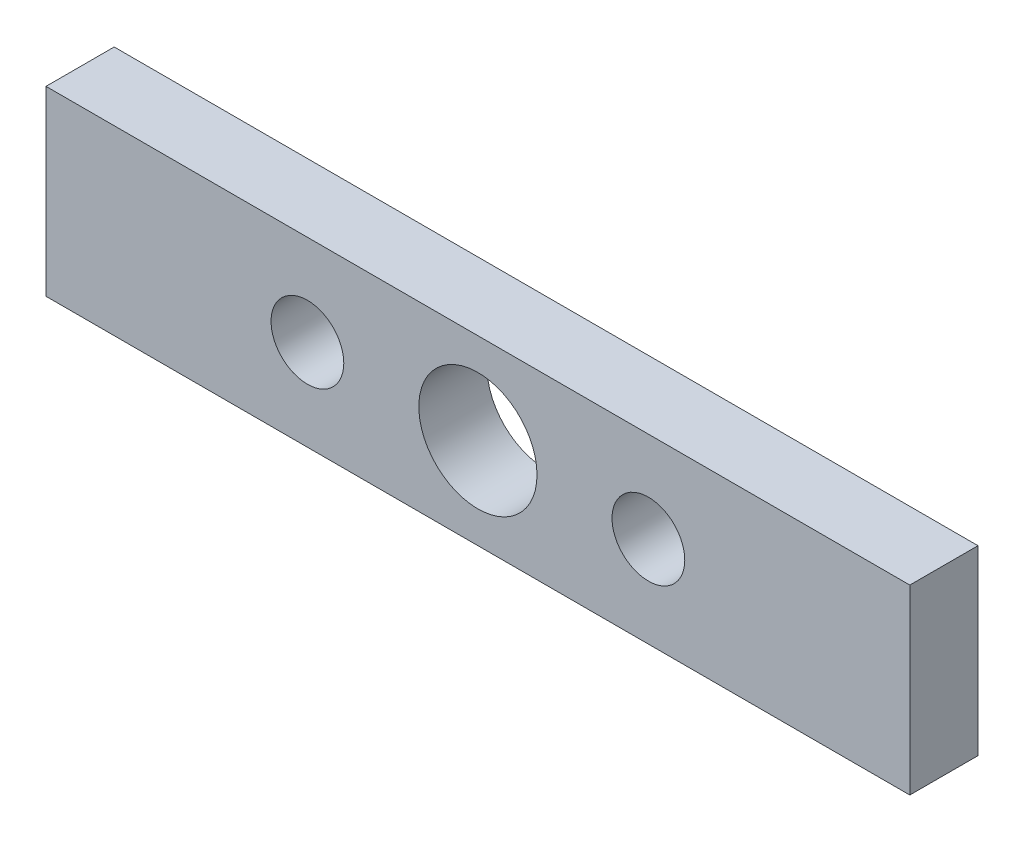
from build123d import *

# Parameters (mm, degrees)
SKETCH1_W           = 38
SKETCH1_H           = 8
SKETCH1_R           = 2.6
SKETCH1_R_2         = 1.6
BOSS_EXTRUDE1_DEPTH = 3


with BuildPart() as part:
    # Sketch1 → Boss-Extrude1 (new body)
    with BuildSketch(Plane.XY):
        Rectangle(SKETCH1_W, SKETCH1_H)
        Circle(SKETCH1_R, mode=Mode.SUBTRACT)
        with Locations((-7.5, 0)):
            Circle(SKETCH1_R_2, mode=Mode.SUBTRACT)
        with Locations((7.5, 0)):
            Circle(SKETCH1_R_2, mode=Mode.SUBTRACT)
    extrude(amount=BOSS_EXTRUDE1_DEPTH)


solid = part.part
